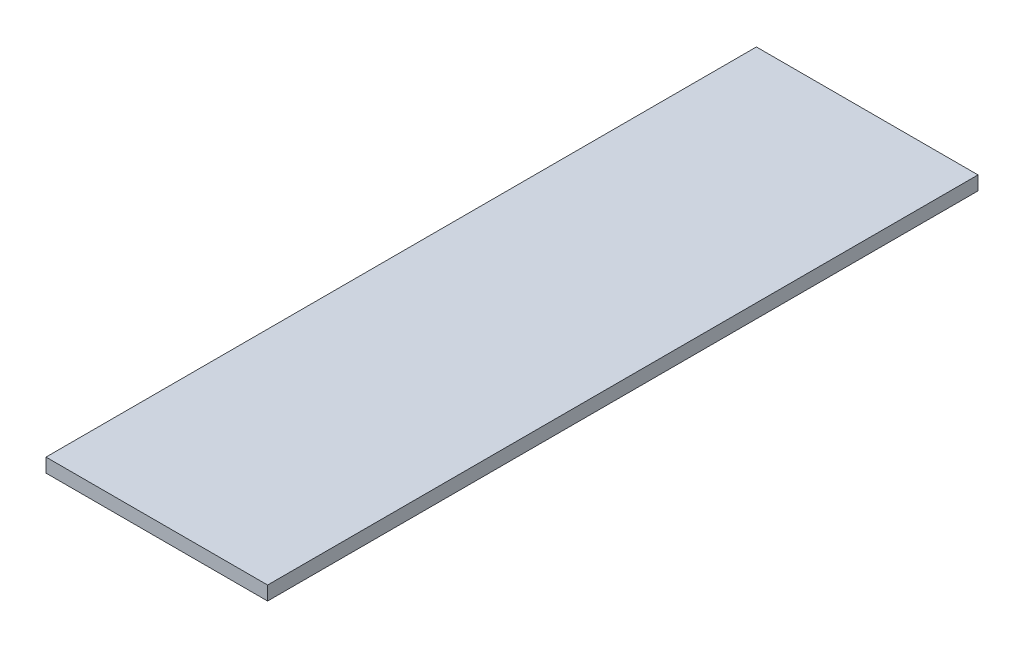
from build123d import *

# Parameters (mm, degrees)
SKETCH_1_W      = 287
SKETCH_1_H      = 920
EXTRUDE_1_DEPTH = 18


with BuildPart() as part:
    # Эскиз1 → Бобышка-Вытянуть1 (new body)
    with BuildSketch(Plane(origin=(0, 0, 0), x_dir=(1, 0, 0), z_dir=(0, 1, 0))):
        Rectangle(SKETCH_1_W, SKETCH_1_H)
    extrude(amount=EXTRUDE_1_DEPTH)


solid = part.part
